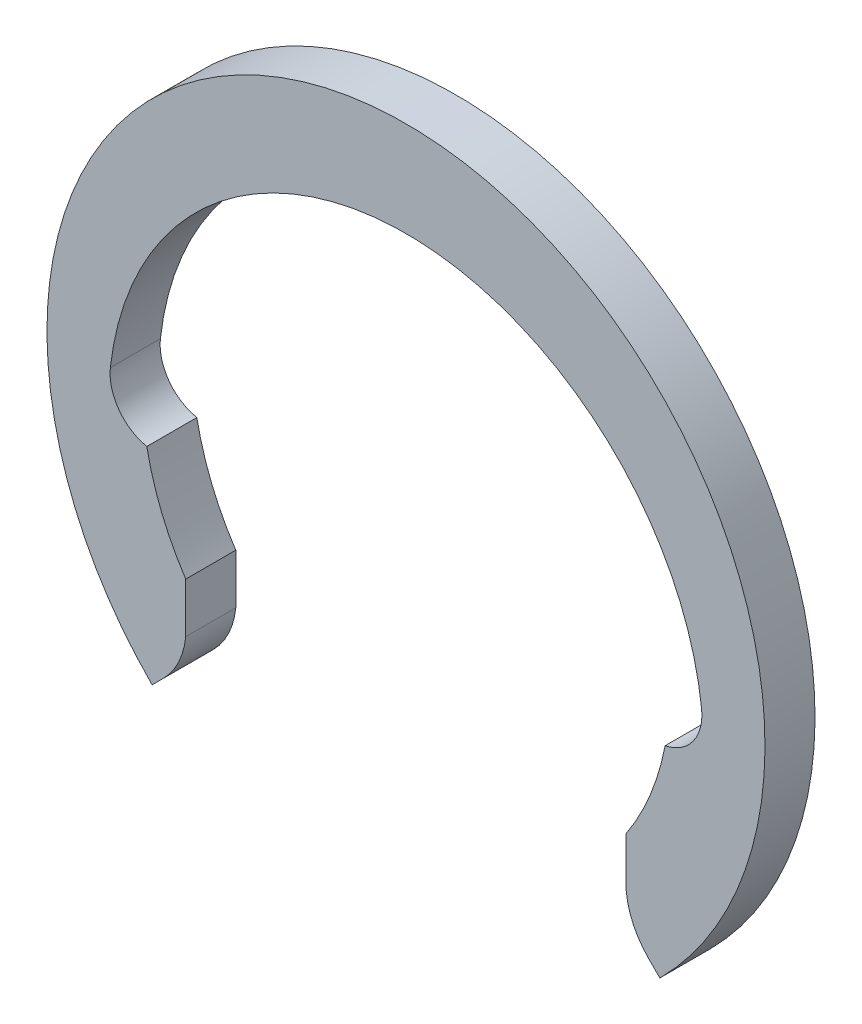
from build123d import *

# Parameters (mm, degrees)
BOSS_EXTRUDE1_DEPTH = 1


with BuildPart() as part:
    # Sketch2 → Boss-Extrude1 (new body)
    with BuildSketch(Plane.XY):
        with BuildLine():
            Line((-4.401739713, -3.903473849), (-4.401739713, -3.405207986))
            Line((-4.401739713, -3.405207986), (-4.401739713, -2.906942122))
            ThreePointArc((-4.401739713, -2.906942122), (-4.884506928, -1.991787406), (-5.179346001, -1))
            ThreePointArc((-5.179346001, -1), (-5.738651784, -0.642015565), (-5.908333333, 0))
            ThreePointArc((-5.908333333, 0), (0, 5.275), (5.908333333, 0))
            ThreePointArc((5.908333333, 0), (5.738651784, -0.642015565), (5.179346001, -1))
            ThreePointArc((5.179346001, -1), (4.884506928, -1.991787406), (4.401739713, -2.906942122))
            Line((4.401739713, -2.906942122), (4.401739713, -3.405207986))
            Line((4.401739713, -3.405207986), (4.401739713, -3.903473849))
            ThreePointArc((4.401739713, -3.903473849), (4.543651106, -4.41534116), (4.849574008, -4.849574008))
            Line((4.849574008, -4.849574008), (5.073491155, -5.073491155))
            ThreePointArc((5.073491155, -5.073491155), (0, 7.175), (-5.073491155, -5.073491155))
            Line((-5.073491155, -5.073491155), (-4.849574008, -4.849574008))
            ThreePointArc((-4.849574008, -4.849574008), (-4.543651106, -4.41534116), (-4.401739713, -3.903473849))
        make_face()
    extrude(amount=BOSS_EXTRUDE1_DEPTH)


solid = part.part
